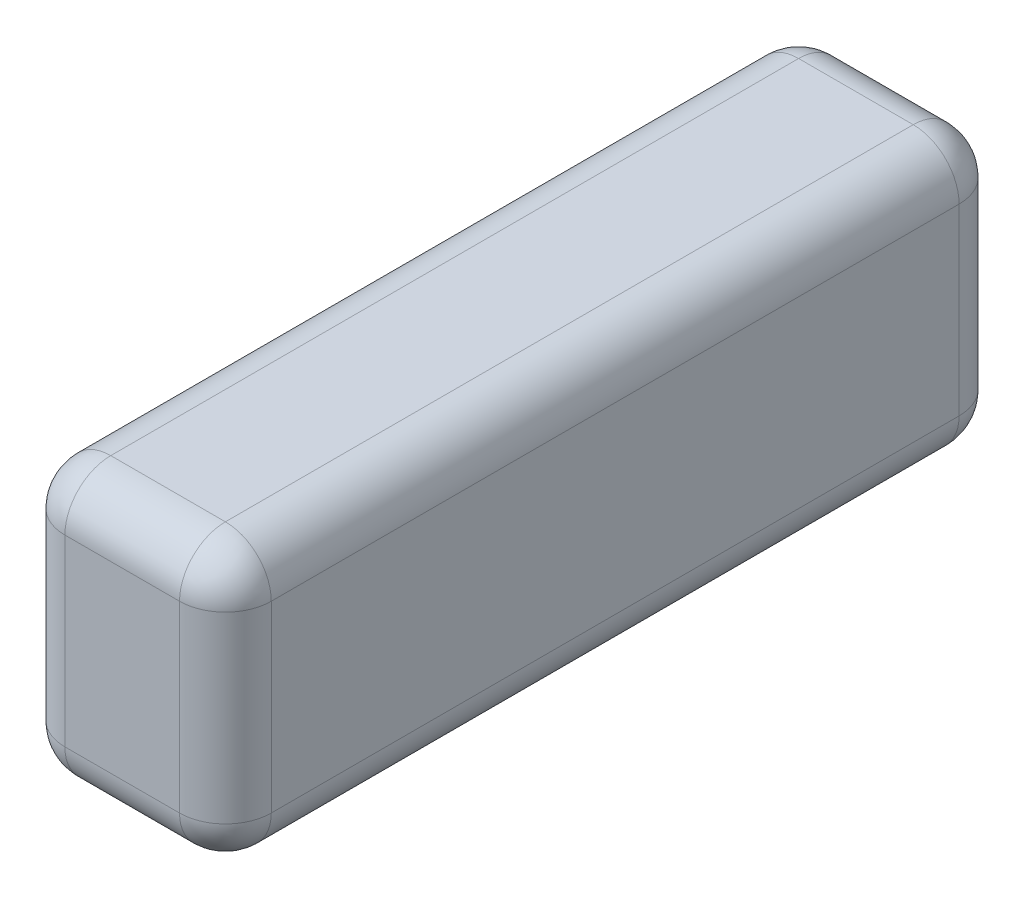
from build123d import *

# Parameters (mm, degrees)
ESQUISSE1_W        = 45
ESQUISSE1_H        = 60
BOSS_EXTRU_1_DEPTH = 170
CONG_1_R           = 10


with BuildPart() as part:
    # Esquisse1 → Boss.-Extru.1 (new body)
    with BuildSketch(Plane.XY):
        with Locations((22.5, 30)):
            Rectangle(ESQUISSE1_W, ESQUISSE1_H)
    extrude(amount=BOSS_EXTRU_1_DEPTH)

    # Congé1
    cong_1_edges = [part.edges().sort_by_distance(p)[0] for p in [
        (45, 30, 170),
        (22.5, 60, 170),
        (0, 30, 170),
        (22.5, 60, 0),
        (45, 30, 0),
        (22.5, 0, 0),
        (0, 30, 0),
        (22.5, 0, 170),
        (0, 60, 85),
        (45, 60, 85),
        (45, 0, 85),
        (0, 0, 85),
    ]]
    fillet(cong_1_edges, radius=CONG_1_R)


solid = part.part
